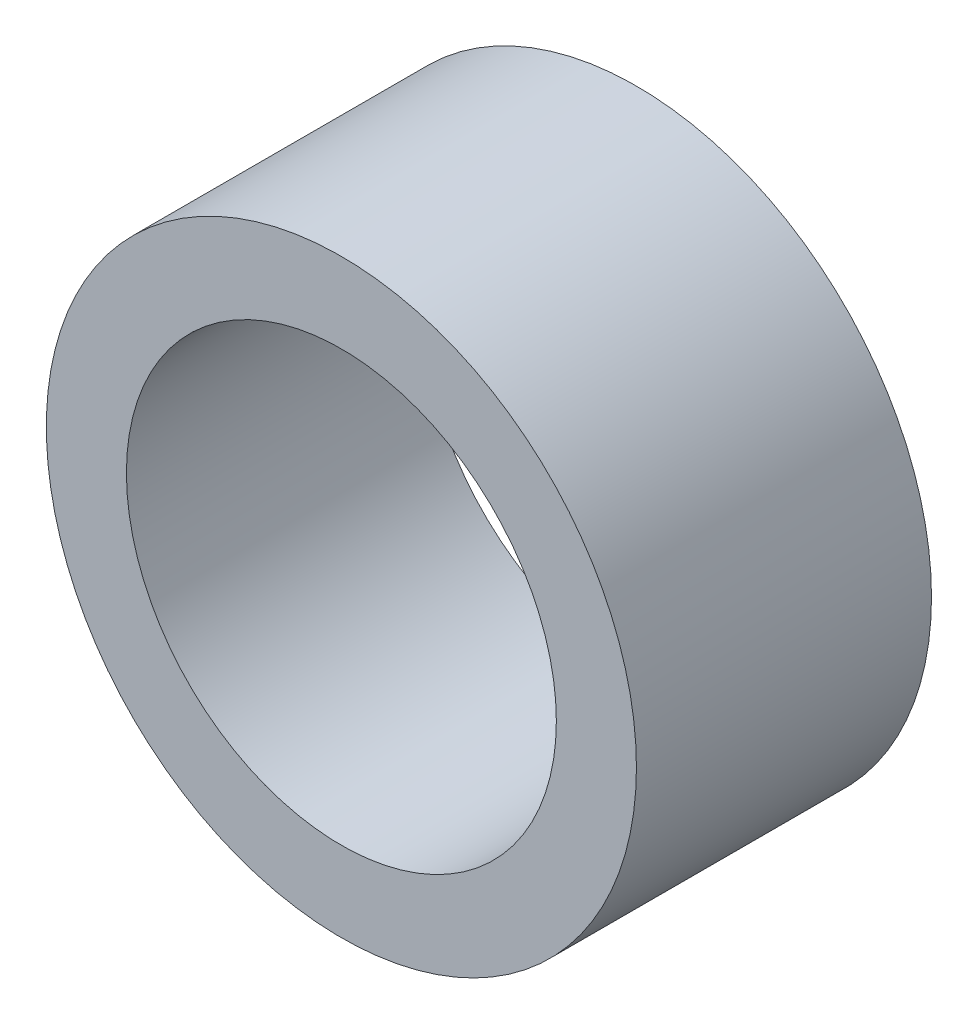
from build123d import *

# Parameters (mm, degrees)
SKETCH1_R           = 4.445
SKETCH1_R_2         = 3.2385
BOSS_EXTRUDE1_DEPTH = 4.445


with BuildPart() as part:
    # Sketch1 → Boss-Extrude1 (new body)
    with BuildSketch(Plane.XY):
        Circle(SKETCH1_R)
        Circle(SKETCH1_R_2, mode=Mode.SUBTRACT)
    extrude(amount=-BOSS_EXTRUDE1_DEPTH)


solid = part.part
